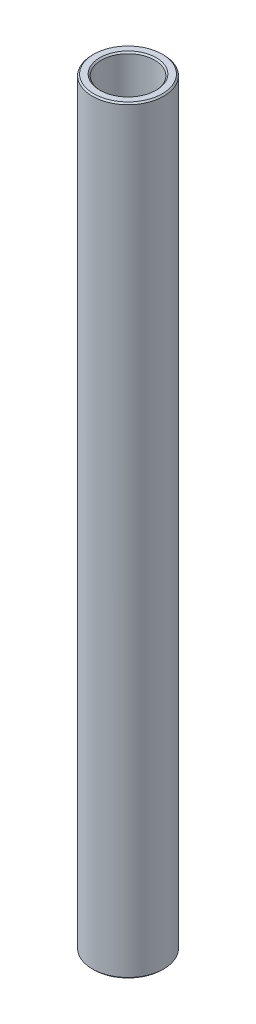
from build123d import *

# Parameters (mm, degrees)
SKETCH1_W     = 1.5875
SKETCH1_H     = 134.937947034
CHAMFER1_SIZE = 0.254


with BuildPart() as part:
    # Sketch1 → Revolve1 (revolve)
    with BuildSketch(Plane.XY):
        with Locations((5.55625, 199.231363447)):
            Rectangle(SKETCH1_W, SKETCH1_H)
    revolve(axis=Axis((0, 122.23738993, 0), (0, 1, 0)))

    # Chamfer1
    chamfer1_edges = [part.edges().sort_by_distance(p)[0] for p in [
        (-6.35, 131.76238993, 0),
        (-6.35, 266.700336964, 0),
        (-4.7625, 266.700336964, 0),
        (-4.7625, 131.76238993, 0),
    ]]
    chamfer(chamfer1_edges, length=CHAMFER1_SIZE)


solid = part.part
